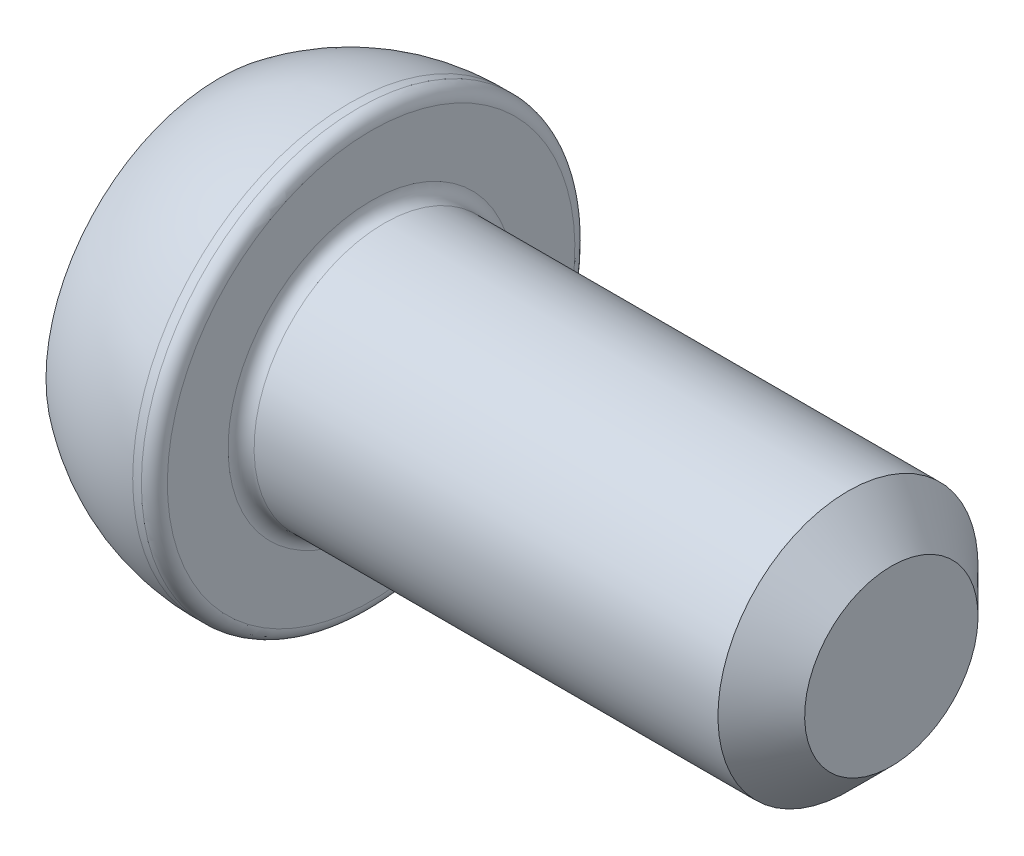
from build123d import *

# Parameters (mm, degrees)
CUT_EXTRUDE_1_DEPTH = 2
FILLET_1_R          = 0.3
CHAMFER_1_SIZE      = 1


with BuildPart() as part:
    # Эскиз1 → Повернуть1 (revolve)
    with BuildSketch(Plane.XY):
        with BuildLine():
            Line((0, 0), (0, 4))
            ThreePointArc((0, 4), (1.41886117, 4.74341649), (3, 5))
            Line((3, 5), (3.5, 5))
            Line((3.5, 5), (3.5, 3))
            Line((3.5, 3), (15.5, 3))
            Line((15.5, 3), (15.5, 0))
            Line((15.5, 0), (0, 0))
        make_face()
    revolve(axis=Axis((15.5, 0, 0), (-1, 0, 0)))

    # Эскиз2 → Вырез-Вытянуть1 (cut)
    with BuildSketch(Plane.ZY):
        Polygon((1.154700538, 2), (-1.154700538, 2), (-2.309401077, 0), (-1.154700538, -2), (1.154700538, -2), (2.309401077, 0), align=None)
    extrude(amount=-CUT_EXTRUDE_1_DEPTH, mode=Mode.SUBTRACT)

    # Скругление1
    fillet_1_edges = [part.edges().sort_by_distance(p)[0] for p in [
        (3.5, -3, 0),
        (3.5, -5, 0),
    ]]
    fillet(fillet_1_edges, radius=FILLET_1_R)

    # Фаска1
    chamfer_1_edges = [part.edges().sort_by_distance(p)[0] for p in [
        (15.5, -3, 0),
    ]]
    chamfer(chamfer_1_edges, length=CHAMFER_1_SIZE)


solid = part.part
